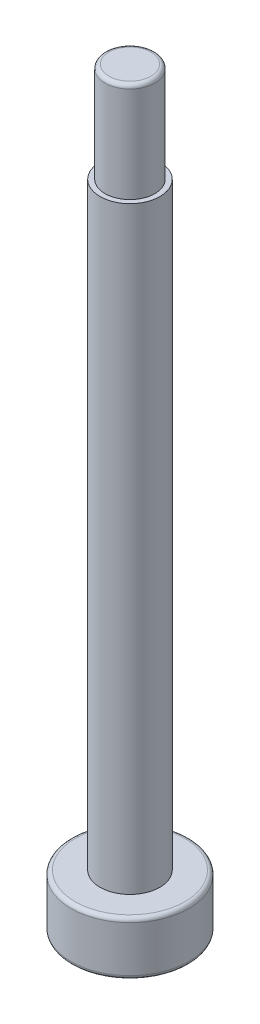
from build123d import *

# Parameters (mm, degrees)
SKETCH_1_R          = 2.95
EXTRUDE_1_DEPTH     = 2.7
SKETCH_2_R          = 1.5
EXTRUDE_2_DEPTH     = 30
SKETCH_3_R          = 1.25
EXTRUDE_3_DEPTH     = 5
CUT_EXTRUDE_1_DEPTH = 2
FILLET_1_R          = 0.2


with BuildPart() as part:
    # 草图1 → 凸台-拉伸1 (new body)
    with BuildSketch(Plane(origin=(0, 0, 0), x_dir=(1, 0, 0), z_dir=(0, 1, 0))):
        Circle(SKETCH_1_R)
    extrude(amount=EXTRUDE_1_DEPTH)

    # 草图2 → 凸台-拉伸2 (add)
    with BuildSketch(Plane(origin=(0, 2.7, 0), x_dir=(1, 0, 0), z_dir=(0, 1, 0))):
        Circle(SKETCH_2_R)
    extrude(amount=EXTRUDE_2_DEPTH)

    # 草图3 → 凸台-拉伸3 (add)
    with BuildSketch(Plane(origin=(0, 32.7, 0), x_dir=(1, 0, 0), z_dir=(0, 1, 0))):
        Circle(SKETCH_3_R)
    extrude(amount=EXTRUDE_3_DEPTH)

    # 草图4 → 切除-拉伸1 (cut)
    with BuildSketch(Plane.XZ):
        Polygon((2.247285488, -0.53201623), (1.584382314, 1.680198207), (-0.662903174, 2.212214437), (-2.247285488, 0.53201623), (-1.584382314, -1.680198207), (0.662903174, -2.212214437), align=None)
    extrude(amount=-CUT_EXTRUDE_1_DEPTH, mode=Mode.SUBTRACT)

    # 圆角1
    fillet_1_edges = [part.edges().sort_by_distance(p)[0] for p in [
        (-1.25, 37.7, 0),
        (-2.95, 0, 0),
        (-2.95, 2.7, 0),
    ]]
    fillet(fillet_1_edges, radius=FILLET_1_R)


solid = part.part
